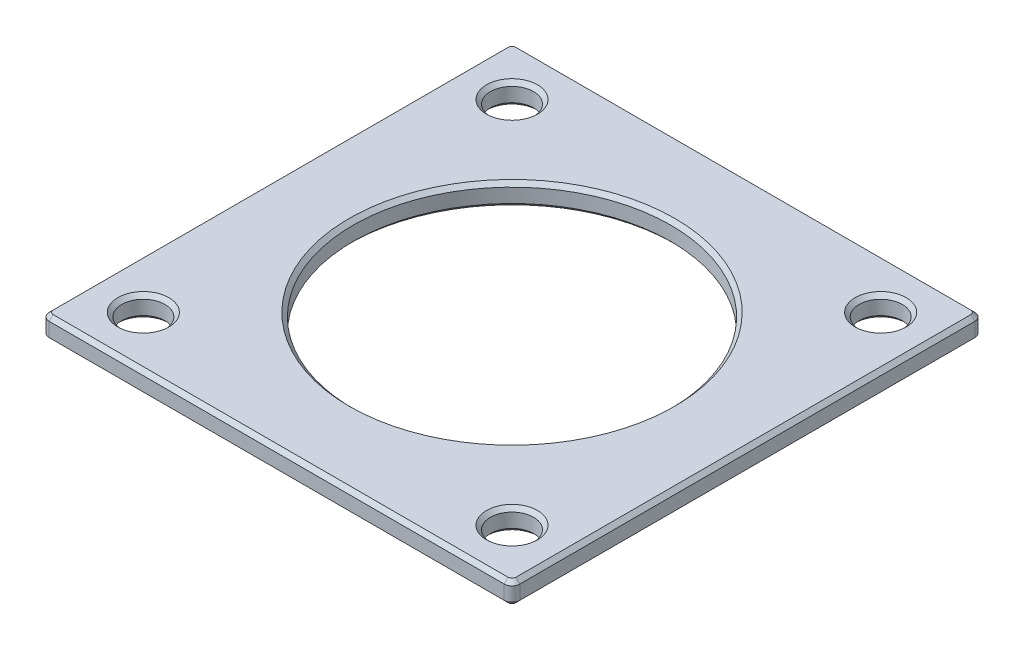
from build123d import *

# Parameters (mm, degrees)
SKETCH1_R           = 20.25
SKETCH1_R_2         = 2.75
BOSS_EXTRUDE1_DEPTH = 2.8
CHAMFER1_SIZE       = 0.5


with BuildPart() as part:
    # Sketch1 → Boss-Extrude1 (new body)
    with BuildSketch(Plane(origin=(0, 0, 0), x_dir=(1, 0, 0), z_dir=(0, 1, 0))):
        with BuildLine():
            Line((-2.397592731, -65.487125506), (-60.397592731, -65.487125506))
            ThreePointArc((-60.397592731, -65.487125506), (-61.104699513, -65.194232288), (-61.397592731, -64.487125506))
            Line((-61.397592731, -64.487125506), (-61.397592731, -6.487125506))
            ThreePointArc((-61.397592731, -6.487125506), (-61.104699513, -5.780018725), (-60.397592731, -5.487125506))
            Line((-60.397592731, -5.487125506), (-2.397592731, -5.487125506))
            ThreePointArc((-2.397592731, -5.487125506), (-1.69048595, -5.780018725), (-1.397592731, -6.487125506))
            Line((-1.397592731, -6.487125506), (-1.397592731, -64.487125506))
            ThreePointArc((-1.397592731, -64.487125506), (-1.69048595, -65.194232288), (-2.397592731, -65.487125506))
        make_face()
        with Locations((-31.397592731, -35.487125506)):
            Circle(SKETCH1_R, mode=Mode.SUBTRACT)
        with Locations((-54.897592731, -11.987125506)):
            Circle(SKETCH1_R_2, mode=Mode.SUBTRACT)
        with Locations((-7.897592731, -11.987125506)):
            Circle(SKETCH1_R_2, mode=Mode.SUBTRACT)
        with Locations((-7.897592731, -58.987125506)):
            Circle(SKETCH1_R_2, mode=Mode.SUBTRACT)
        with Locations((-54.897592731, -58.987125506)):
            Circle(SKETCH1_R_2, mode=Mode.SUBTRACT)
    extrude(amount=BOSS_EXTRUDE1_DEPTH)

    # Chamfer1
    chamfer1_edges = [part.edges().sort_by_distance(p)[0] for p in [
        (-1.397592731, 0, 35.487125506),
        (-1.69048595, 0, 65.194232288),
        (-31.397592731, 0, 65.487125506),
        (-61.104699513, 0, 65.194232288),
        (-1.69048595, 2.8, 65.194232288),
        (-1.397592731, 2.8, 35.487125506),
        (-1.69048595, 2.8, 5.780018725),
        (-51.647592731, 0, 35.487125506),
        (-51.647592731, 2.8, 35.487125506),
        (-31.397592731, 2.8, 5.487125506),
        (-57.647592731, 0, 11.987125506),
        (-57.647592731, 2.8, 11.987125506),
        (-61.104699513, 2.8, 5.780018725),
        (-10.647592731, 0, 11.987125506),
        (-10.647592731, 2.8, 11.987125506),
        (-61.397592731, 2.8, 35.487125506),
        (-10.647592731, 0, 58.987125506),
        (-10.647592731, 2.8, 58.987125506),
        (-57.647592731, 0, 58.987125506),
        (-57.647592731, 2.8, 58.987125506),
        (-61.104699513, 2.8, 65.194232288),
        (-61.397592731, 0, 35.487125506),
        (-31.397592731, 2.8, 65.487125506),
        (-61.104699513, 0, 5.780018725),
        (-31.397592731, 0, 5.487125506),
        (-1.69048595, 0, 5.780018725),
    ]]
    chamfer(chamfer1_edges, length=CHAMFER1_SIZE)


solid = part.part
